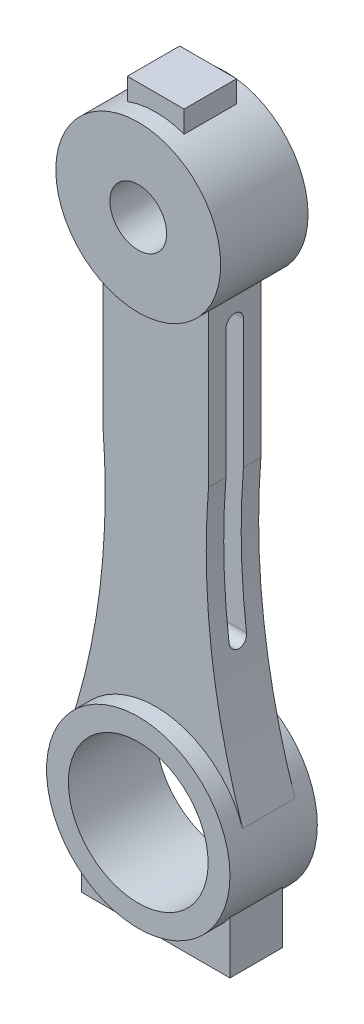
from build123d import *

# Parameters (mm, degrees)
IZIM2_R                       = 18.879465786
IZIM2_R_2                     = 6.5
Y_KSEKLIK_EKSTR_ZYON1_DEPTH   = 10
IZIM2_R_3                     = 21
IZIM2_R_4                     = 16
Y_KSEKLIK_EKSTR_ZYON1_2_DEPTH = 10
Y_KSEKLIK_EKSTR_ZYON3_DEPTH   = 6
Y_KSEKLIK_EKSTR_ZYON4_DEPTH   = 6
KES_EKSTR_ZYON1_START         = 6
KES_EKSTR_ZYON1_DEPTH         = 141.191007225


with BuildPart() as part:
    # Çizim2 → Yükseklik-Ekstrüzyon1 (new, symmetric)
    with BuildSketch(Plane.XY):
        Circle(IZIM2_R)
        Circle(IZIM2_R_2, mode=Mode.SUBTRACT)
    extrude(amount=Y_KSEKLIK_EKSTR_ZYON1_DEPTH, both=True)



with BuildPart() as body_2:
    # Çizim2 → Y_kseklik-Ekstr_zyon1 2 (new, symmetric)
    with BuildSketch(Plane.XY):
        with Locations((0, -120)):
            Circle(IZIM2_R_3)
        with Locations((0, -120)):
            Circle(IZIM2_R_4, mode=Mode.SUBTRACT)
    extrude(amount=Y_KSEKLIK_EKSTR_ZYON1_2_DEPTH, both=True)


with BuildPart() as part_1:
    add(part.part)

    add(body_2.part)  # Yükseklik-Ekstrüzyon3 merges body 2
    # Çizim2<8> → Yükseklik-Ekstrüzyon3 (add, symmetric)
    with BuildSketch(Plane.XY):
        with BuildLine():
            ThreePointArc((12.082858103, -14.506507796), (0, -18.879465786), (-12.082858103, -14.506507796))
            Line((-12.082858103, -14.506507796), (-12.082858103, -49.506507796))
            ThreePointArc((-12.082858103, -49.506507796), (-12.752926263, -81.777932893), (-19.888250818, -113.257783792))
            ThreePointArc((-19.888250818, -113.257783792), (0, -99), (19.888250818, -113.257783792))
            ThreePointArc((19.888250818, -113.257783792), (12.752926263, -81.777932893), (12.082858103, -49.506507796))
            Line((12.082858103, -49.506507796), (12.082858103, -14.506507796))
        make_face()
    extrude(amount=Y_KSEKLIK_EKSTR_ZYON3_DEPTH, both=True)

    # Çizim2<9> → Yükseklik-Ekstrüzyon4 (add, symmetric)
    with BuildSketch(Plane.XY):
        with BuildLine():
            Line((-6.5, 22.725242689), (-6.5, 17.725242689))
            ThreePointArc((-6.5, 17.725242689), (0, 18.879465786), (6.5, 17.725242689))
            Line((6.5, 17.725242689), (6.5, 22.725242689))
            Line((6.5, 22.725242689), (-6.5, 22.725242689))
        make_face()
        with BuildLine():
            ThreePointArc((17, -132.328828006), (0, -141), (-17, -132.328828006))
            Line((-17, -132.328828006), (-17, -144.328828006))
            Line((-17, -144.328828006), (17, -144.328828006))
            Line((17, -144.328828006), (17, -132.328828006))
        make_face()
    extrude(amount=Y_KSEKLIK_EKSTR_ZYON4_DEPTH, both=True)

    # Çizim4 → Kes-Ekstrüzyon1 (cut, through all)
    with BuildSketch(Plane(origin=(0, 0, 0), x_dir=(0, 0, -1), z_dir=(1, 0, 0)).offset(KES_EKSTR_ZYON1_START)):
        with BuildLine():
            Line((2, -20), (2, -82))
            ThreePointArc((2, -82), (0, -84), (-2, -82))
            Line((-2, -82), (-2, -20))
            ThreePointArc((-2, -20), (0, -18), (2, -20))
        make_face()
    kes_ekstr_zyon1 = extrude(amount=KES_EKSTR_ZYON1_DEPTH, mode=Mode.SUBTRACT)

    # Aynalama1: Kes-Ekstrüzyon1 across plane
    add(kes_ekstr_zyon1.mirror(Plane(origin=(0, 0, 0), x_dir=(0, 0, 1), z_dir=(1, 0, 0))), mode=Mode.SUBTRACT)


solid = part_1.part
